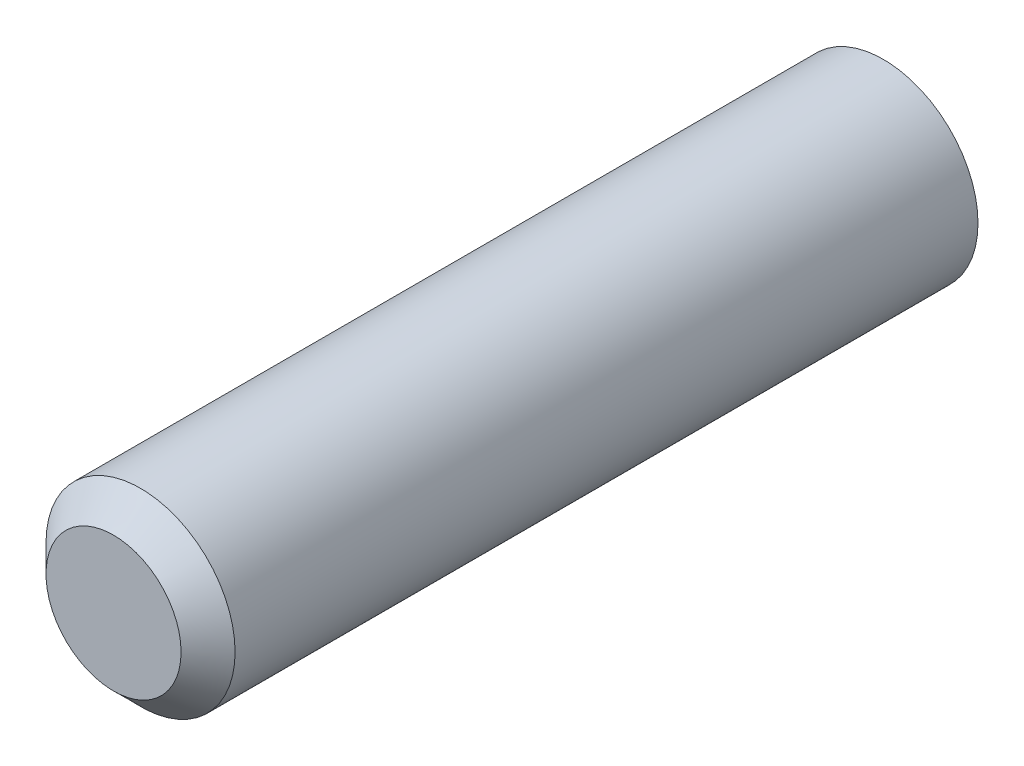
from build123d import *

# Parameters (mm, degrees)
ESBO_O1_R                = 70
RESSALTO_EXTRUS_O1_DEPTH = 570
CHANFRO1_SIZE            = 20


with BuildPart() as part:
    # Esboço1 → Ressalto-extrusão1 (new body)
    with BuildSketch(Plane.XY):
        Circle(ESBO_O1_R)
    extrude(amount=RESSALTO_EXTRUS_O1_DEPTH)

    # Chanfro1
    chanfro1_edges = [part.edges().sort_by_distance(p)[0] for p in [
        (-70, 0, 570),
    ]]
    chamfer(chanfro1_edges, length=CHANFRO1_SIZE)


solid = part.part
